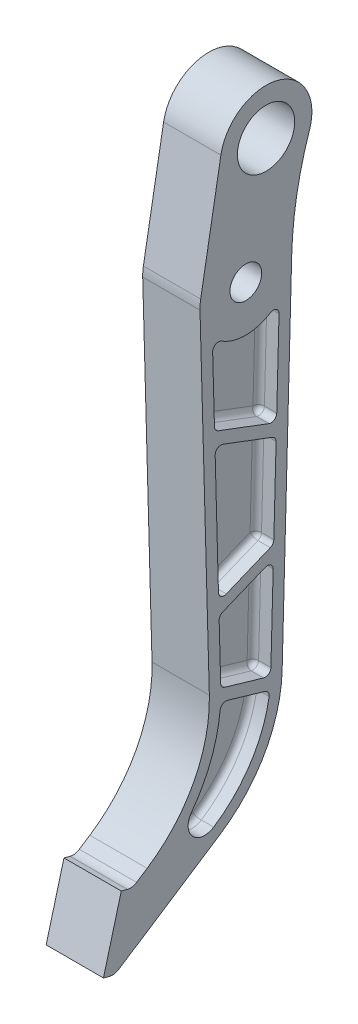
from build123d import *

# Parameters (mm, degrees)
SKETCH1_R            = 8.8003507
SKETCH1_R_2          = 15.875
BOSS_EXTRUDE1_DEPTH  = 15.875
CUT_EXTRUDE1_DEPTH   = 10
FILLET1_R            = 3.175
FILLET1_OF_MIRROR2_R = 3.175


with BuildPart() as part:
    # Sketch1 → Boss-Extrude1 (new body, symmetric)
    with BuildSketch(Plane(origin=(0, 0, 0), x_dir=(0, 0, -1), z_dir=(1, 0, 0))):
        with BuildLine():
            Line((-25.39034411, -0.700304185), (-20.223925011, -188.014847764))
            ThreePointArc((-20.223925011, -188.014847764), (-28.875615942, -225.436838118), (-54.68211929, -253.884711554))
            Line((-54.68211929, -253.884711554), (-60.516881835, -257.701373117))
            ThreePointArc((-60.516881835, -257.701373117), (-62.989212347, -258.657461897), (-65.636452609, -258.520922845))
            Line((-65.636452609, -258.520922845), (-69.027039329, -257.612417871))
            Line((-69.027039329, -257.612417871), (-78.888044947, -294.414191853))
            Line((-78.888044947, -294.414191853), (-75.497458227, -295.322696826))
            ThreePointArc((-75.497458227, -295.322696826), (-72.850217966, -295.459235879), (-70.377887453, -294.503147099))
            Line((-70.377887453, -294.503147099), (-14.336567795, -257.845142759))
            ThreePointArc((-14.336567795, -257.845142759), (10.482969023, -231.222969231), (20.123027121, -196.125692826))
            Line((20.123027121, -196.125692826), (25.4, 0))
            ThreePointArc((25.4, 0), (28.25967608, 28.056462685), (35.262211937, 55.375088881))
            ThreePointArc((35.262211937, 55.375088881), (17.482473415, 88.109954247), (-13.817353652, 67.910663713))
            Line((-13.817353652, 67.910663713), (-25.014116927, 4.410663713))
            ThreePointArc((-25.014116927, 4.410663713), (-25.331461097, 1.86469265), (-25.39034411, -0.700304185))
        make_face()
        Circle(SKETCH1_R, mode=Mode.SUBTRACT)
        with Locations((11.196763275, 63.5)):
            Circle(SKETCH1_R_2, mode=Mode.SUBTRACT)
    extrude(amount=BOSS_EXTRUDE1_DEPTH, both=True)

    # Sketch2 → Cut-Extrude1 (cut)
    with BuildSketch(Plane(origin=(15.875, 0, 0), x_dir=(0, 0, -1), z_dir=(1, 0, 0))):
        with BuildLine():
            Line((-11.660302985, -188.490127485), (9.818309103, -194.793607776))
            ThreePointArc((9.818309103, -194.793607776), (12.580917397, -194.314044839), (13.886242269, -191.832490452))
            Line((13.886242269, -191.832490452), (15.141700078, -145.171736569))
            ThreePointArc((15.141700078, -145.171736569), (13.770751444, -142.472881917), (10.760959128, -142.149668662))
            Line((10.760959128, -142.149668662), (-12.818942026, -151.840344616))
            ThreePointArc((-12.818942026, -151.840344616), (-14.273641559, -153.045956724), (-14.785845463, -154.864554658))
            Line((-14.785845463, -154.864554658), (-13.940014207, -185.531152296))
            ThreePointArc((-13.940014207, -185.531152296), (-13.281332503, -187.381355252), (-11.660302985, -188.490127485))
        make_face()
        with BuildLine():
            Line((15.515269566, -131.287531301), (16.765792896, -84.810173886))
            ThreePointArc((16.765792896, -84.810173886), (16.228003809, -82.955088584), (14.71468148, -81.754916051))
            Line((14.71468148, -81.754916051), (-12.693209932, -71.393513614))
            ThreePointArc((-12.693209932, -71.393513614), (-15.656229887, -71.776100059), (-16.989779352, -74.449581958))
            Line((-16.989779352, -74.449581958), (-15.174226134, -141.292142862))
            ThreePointArc((-15.174226134, -141.292142862), (-13.732014902, -143.867162368), (-10.793507095, -144.142608485))
            Line((-10.793507095, -144.142608485), (13.548307769, -134.138807433))
            ThreePointArc((13.548307769, -134.138807433), (14.954876957, -133.005038153), (15.515269566, -131.287531301))
        make_face()
        with BuildLine():
            Line((-15.331296871, -63.607584159), (12.830833159, -74.254122353))
            ThreePointArc((12.830833159, -74.254122353), (15.723262531, -73.920322691), (17.12742449, -71.369656293))
            Line((17.12742449, -71.369656293), (18.394713184, -24.269191925))
            ThreePointArc((18.394713184, -24.269191925), (16.792875178, -21.425282131), (13.529654942, -21.496707589))
            ThreePointArc((13.529654942, -21.496707589), (0.003660623, -25.399999736), (-13.523458211, -21.500606457))
            ThreePointArc((-13.523458211, -21.500606457), (-16.787232142, -21.430425741), (-18.387683501, -24.275720287))
            Line((-18.387683501, -24.275720287), (-17.382349928, -60.725260234))
            ThreePointArc((-17.382349928, -60.725260234), (-16.7954463, -62.478544936), (-15.331296871, -63.607584159))
        make_face()
        with BuildLine():
            Line((-10.195205463, -195.537911468), (10.666732473, -201.660412031))
            ThreePointArc((10.666732473, -201.660412031), (12.458283079, -203.013407124), (12.907034325, -205.213150658))
            ThreePointArc((12.907034325, -205.213150658), (2.53678877, -232.111442282), (-17.812637633, -252.531063489))
            ThreePointArc((-17.812637633, -252.531063489), (-29.49364525, -251.143961365), (-30.171678071, -239.400441332))
            ThreePointArc((-30.171678071, -239.400441332), (-19.412569014, -219.918686135), (-14.248756518, -198.270770444))
            ThreePointArc((-14.248756518, -198.270770444), (-12.864146304, -195.95184033), (-10.195205463, -195.537911468))
        make_face()
    cut_extrude1 = extrude(amount=-CUT_EXTRUDE1_DEPTH, mode=Mode.SUBTRACT)

    # Fillet1
    fillet1_edges = [part.edges().sort_by_distance(p)[0] for p in [
        (5.875, -219.918686135, 19.412569014),
        (5.875, -195.95184033, 12.864146304),
        (5.875, -198.59916175, -0.235763505),
        (5.875, -203.013407124, -12.458283079),
        (5.875, -232.111442282, -2.53678877),
        (5.875, -251.143961365, 29.49364525),
        (5.875, -194.314044839, -12.580917397),
        (5.875, -191.64186763, 0.920996941),
        (5.875, -187.381355252, 13.281332503),
        (5.875, -170.197853477, 14.362929835),
        (5.875, -153.045956724, 14.273641559),
        (5.875, -146.995006639, 1.028991449),
        (5.875, -142.472881917, -13.770751444),
        (5.875, -168.50211351, -14.513971173),
        (5.875, -133.005038153, -14.954876957),
        (5.875, -139.140707959, -1.377400337),
        (5.875, -143.867162368, 13.732014902),
        (5.875, -107.87086241, 16.082002743),
        (5.875, -71.776100059, 15.656229887),
        (5.875, -76.574214832, -1.010735774),
        (5.875, -82.955088584, -16.228003809),
        (5.875, -108.048852594, -16.140531231),
        (5.875, -21.425282131, -16.792875178),
        (5.875, -47.819424109, -17.761068837),
        (5.875, -73.920322691, -15.723262531),
        (5.875, -68.930853256, 1.250231856),
        (5.875, -62.478544936, 16.7954463),
        (5.875, -42.500490261, 17.885016715),
        (5.875, -21.430425741, 16.787232142),
        (5.875, -25.399999736, -0.003660623),
    ]]
    fillet(fillet1_edges, radius=FILLET1_R)

    # Mirror2: Cut-Extrude1 across plane
    add(cut_extrude1.mirror(Plane(origin=(0, 0, 0), x_dir=(0, 0, 1), z_dir=(1, 0, 0))), mode=Mode.SUBTRACT)

    # Fillet1 of Mirror2
    fillet1_of_mirror2_edges = [part.edges().sort_by_distance(p)[0] for p in [
        (-5.875, -219.918686135, 19.412569014),
        (-5.875, -195.95184033, 12.864146304),
        (-5.875, -198.59916175, -0.235763505),
        (-5.875, -203.013407124, -12.458283079),
        (-5.875, -232.111442282, -2.53678877),
        (-5.875, -251.143961365, 29.49364525),
        (-5.875, -194.314044839, -12.580917397),
        (-5.875, -191.64186763, 0.920996941),
        (-5.875, -187.381355252, 13.281332503),
        (-5.875, -170.197853477, 14.362929835),
        (-5.875, -153.045956724, 14.273641559),
        (-5.875, -146.995006639, 1.028991449),
        (-5.875, -142.472881917, -13.770751444),
        (-5.875, -168.50211351, -14.513971173),
        (-5.875, -133.005038153, -14.954876957),
        (-5.875, -139.140707959, -1.377400337),
        (-5.875, -143.867162368, 13.732014902),
        (-5.875, -107.87086241, 16.082002743),
        (-5.875, -71.776100059, 15.656229887),
        (-5.875, -76.574214832, -1.010735774),
        (-5.875, -82.955088584, -16.228003809),
        (-5.875, -108.048852594, -16.140531231),
        (-5.875, -21.425282131, -16.792875178),
        (-5.875, -47.819424109, -17.761068837),
        (-5.875, -73.920322691, -15.723262531),
        (-5.875, -68.930853256, 1.250231856),
        (-5.875, -62.478544936, 16.7954463),
        (-5.875, -42.500490261, 17.885016715),
        (-5.875, -21.430425741, 16.787232142),
        (-5.875, -25.399999736, -0.003660623),
    ]]
    fillet(fillet1_of_mirror2_edges, radius=FILLET1_OF_MIRROR2_R)


solid = part.part
